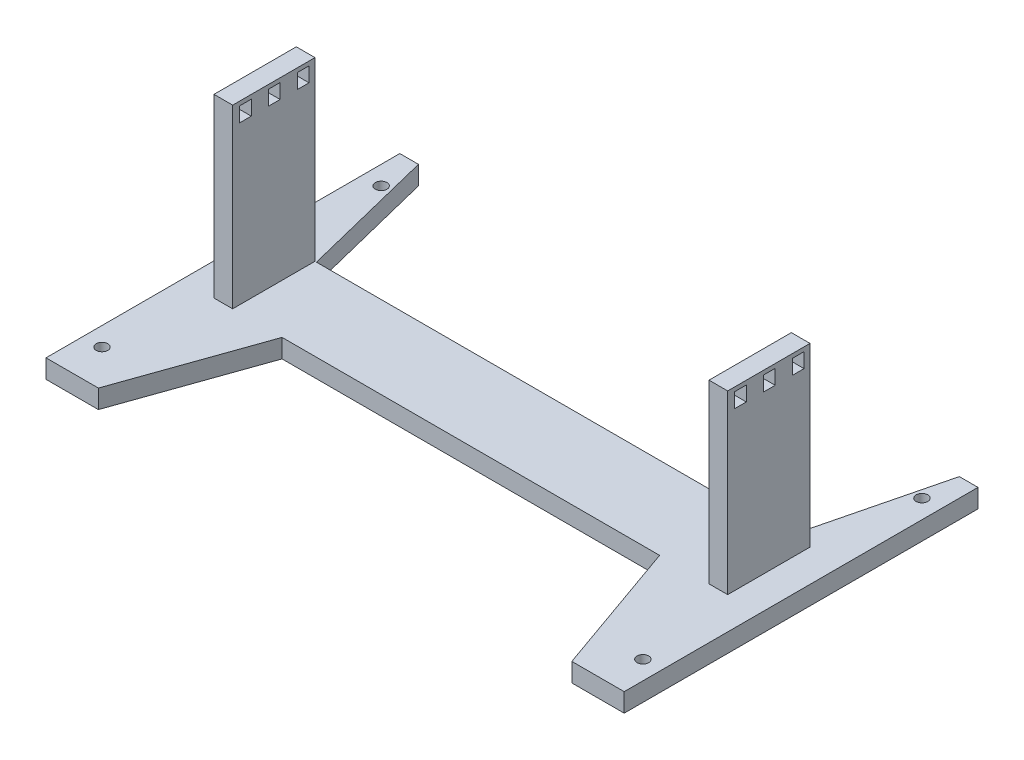
from build123d import *

# Parameters (mm, degrees)
SKETCH_1_R          = 1.984
EXTRUDE_1_DEPTH     = 6.35
SKETCH_2_W          = 6.35
SKETCH_2_H          = 28
EXTRUDE_2_DEPTH     = 60
CUT_EXTRUDE_1_DEPTH = 250


with BuildPart() as part:
    # 草图1 → 凸台-拉伸1 (new body)
    with BuildSketch(Plane(origin=(0, 0, 0), x_dir=(1, 0, 0), z_dir=(0, 1, 0))):
        Polygon((98.023064942, -74.926838383), (91.673064942, -74.926838383), (80.206659609, -74.926838383), (63.904311177, -28.766838383), (-64.490991959, -28.766838383), (-80.793340391, -74.926838383), (-92.259745724, -74.926838383), (-98.609745724, -74.926838383), (-98.609745724, 45.393161617), (-92.259745724, 45.393161617), (-80.793340391, -0.766838383), (-64.490991959, -0.766838383), (63.904311177, -0.766838383), (80.206659609, -0.766838383), (91.673064942, 45.393161617), (98.023064942, 45.393161617), align=None)
        with Locations((91.673064942, -62.226838383)):
            Circle(SKETCH_1_R, mode=Mode.SUBTRACT)
        with Locations((91.673064942, 32.693161617)):
            Circle(SKETCH_1_R, mode=Mode.SUBTRACT)
        with Locations((-92.259745724, -62.226838383)):
            Circle(SKETCH_1_R, mode=Mode.SUBTRACT)
        with Locations((-92.259745724, 32.693161617)):
            Circle(SKETCH_1_R, mode=Mode.SUBTRACT)
    extrude(amount=EXTRUDE_1_DEPTH)

    # 草图2 → 凸台-拉伸2 (add)
    with BuildSketch(Plane(origin=(0, 6.35, 0), x_dir=(1, 0, 0), z_dir=(0, 1, 0))):
        with Locations((-84.468340391, -14.766838383)):
            Rectangle(SKETCH_2_W, SKETCH_2_H)
        with Locations((83.881659609, -14.766838383)):
            Rectangle(SKETCH_2_W, SKETCH_2_H)
    extrude(amount=EXTRUDE_2_DEPTH)

    # 草图3 → 切除-拉伸1 (cut)
    with BuildSketch(Plane(origin=(87.056659609, 0, 0), x_dir=(0, 0, -1), z_dir=(1, 0, 0))):
        Polygon((-22.436838383, 62.44), (-22.436838383, 59.94), (-26.436838383, 59.94), (-26.436838383, 64.94), (-22.436838383, 64.94), align=None)
        Polygon((-16.616838383, 62.44), (-16.616838383, 59.94), (-12.616838383, 59.94), (-12.616838383, 64.94), (-16.616838383, 64.94), align=None)
        Polygon((-6.796838383, 62.44), (-6.796838383, 64.94), (-2.796838383, 64.94), (-2.796838383, 59.94), (-6.796838383, 59.94), align=None)
    extrude(amount=-CUT_EXTRUDE_1_DEPTH, mode=Mode.SUBTRACT)


solid = part.part
